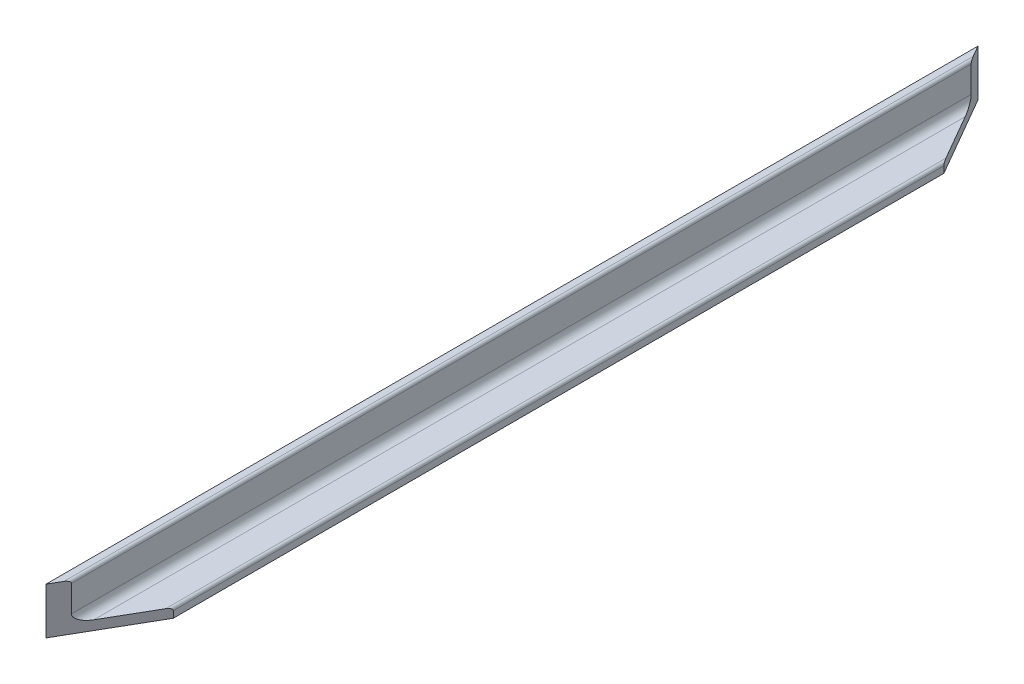
from build123d import *

# Parameters (mm, degrees)
EXTRUDE_1_DEPTH     = 400
CUT_EXTRUDE_1_DEPTH = 21
CUT_EXTRUDE_2_DEPTH = 21


with BuildPart() as part:
    # Эскиз1 → Бобышка-Вытянуть1 (new body)
    with BuildSketch(Plane.XY):
        with BuildLine():
            Line((-7.5, 12.5), (-7.5, -7.5))
            Line((-7.5, -7.5), (12.5, -7.5))
            Line((12.5, -7.5), (12.5, -4.7))
            ThreePointArc((12.5, -4.7), (12.148528137, -3.851471863), (11.3, -3.5))
            Line((11.3, -3.5), (0, -3.5))
            ThreePointArc((0, -3.5), (-2.474873734, -2.474873734), (-3.5, 0))
            Line((-3.5, 0), (-3.5, 11.3))
            ThreePointArc((-3.5, 11.3), (-3.851471863, 12.148528137), (-4.7, 12.5))
            Line((-4.7, 12.5), (-7.5, 12.5))
        make_face()
    extrude(amount=EXTRUDE_1_DEPTH)

    # Эскиз4 → Вырез-Вытянуть1 (cut, through all)
    with BuildSketch(Plane.XZ.offset(7.5)):
        Polygon((-7.5, 0), (12.5, 0), (12.5, 34.641016151), align=None)
    extrude(amount=-CUT_EXTRUDE_1_DEPTH, mode=Mode.SUBTRACT)

    # Эскиз5 → Вырез-Вытянуть2 (cut, through all)
    with BuildSketch(Plane.XZ.offset(7.5)):
        Polygon((12.5, 400), (-7.5, 400), (12.5, 365.358983849), align=None)
    extrude(amount=-CUT_EXTRUDE_2_DEPTH, mode=Mode.SUBTRACT)


solid = part.part
